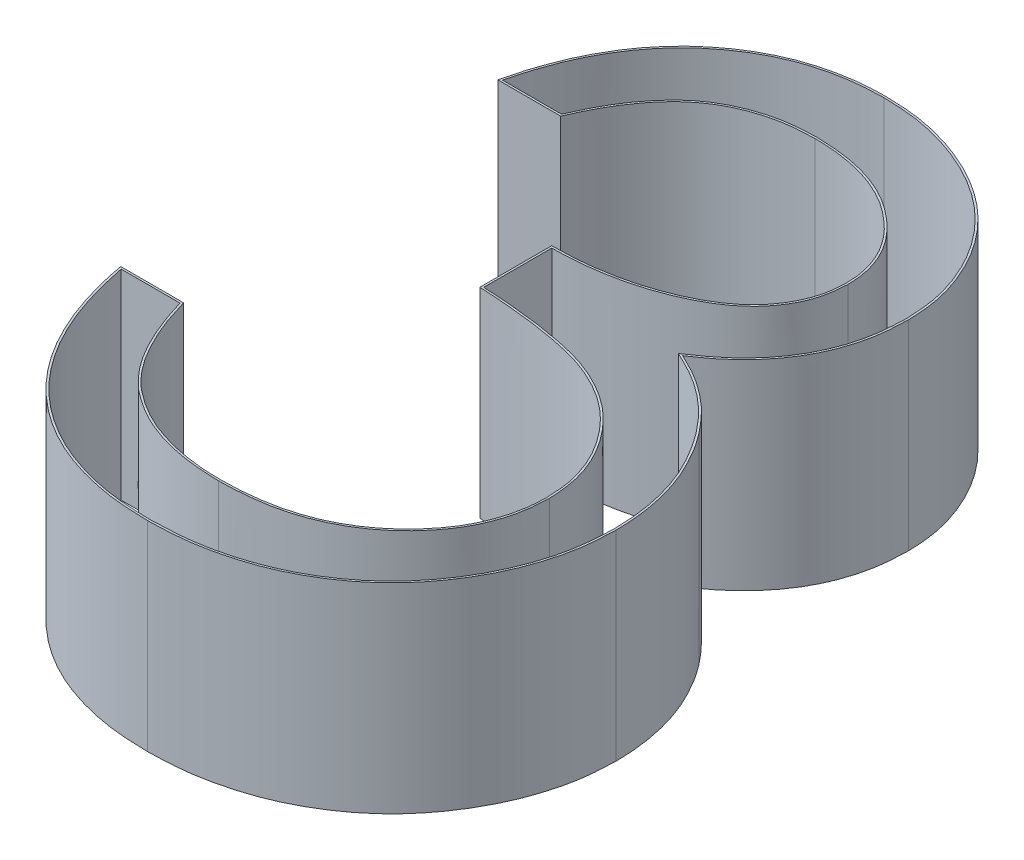
from build123d import *

# Parameters (mm, degrees)
BOSS_EXTRUDE1_DEPTH = 1
CUT_EXTRUDE1_DEPTH  = 1


with BuildPart() as part:
    # Sketch1 → Boss-Extrude1 (new body)
    with BuildSketch(Plane(origin=(0, 0, 0), x_dir=(1, 0, 0), z_dir=(0, 1, 0))):
        with BuildLine():
            Line((0.583333333, 2.692307692), (0.269230769, 2.692307692))
            add(Edge.make_bspline(
                [(0.269230769, 2.692307692), (0.27774032, 2.727540176), (0.294375795, 2.796416801), (0.329073369, 2.894824062), (0.366872624, 2.987947583), (0.412261729, 3.074043657), (0.461770483, 3.154842559), (0.518493204, 3.228511684), (0.579812927, 3.296924649), (0.647637876, 3.357637887), (0.718766538, 3.412615616), (0.794201158, 3.459490673), (0.872424051, 3.499814826), (0.953977184, 3.533035058), (1.039103356, 3.558060582), (1.127032979, 3.576217387), (1.217996479, 3.588008502), (1.27974407, 3.589159265), (1.311097756, 3.58974359)],
                knots=[0, 0, 0, 0, 0.000108665, 0.000212431, 0.000312691, 0.000409905, 0.000504067, 0.000596618, 0.000688443, 0.000779278, 0.000869306, 0.00095782, 0.001045306, 0.001133058, 0.001221569, 0.001311085, 0.001402223, 0.001496238, 0.001496238, 0.001496238, 0.001496238], degree=3))
            add(Edge.make_bspline(
                [(1.311097756, 3.58974359), (1.356780498, 3.588364359), (1.447149509, 3.585635984), (1.579912556, 3.560721548), (1.707939375, 3.521296415), (1.829828623, 3.466822688), (1.943047056, 3.399635375), (2.043783243, 3.319670638), (2.130671753, 3.228471337), (2.203566131, 3.127738772), (2.26064113, 3.020083263), (2.302727504, 2.909283106), (2.328349185, 2.795601134), (2.331669741, 2.718843855), (2.333333333, 2.680388622)],
                knots=[0, 0, 0, 0, 0.000136936, 0.000270885, 0.000403723, 0.000538055, 0.000670441, 0.000797677, 0.000922646, 0.001047185, 0.00116951, 0.001287103, 0.001401935, 0.001517226, 0.001517226, 0.001517226, 0.001517226], degree=3))
            add(Edge.make_bspline(
                [(2.333333333, 2.680388622), (2.332169742, 2.643381827), (2.329892775, 2.570965273), (2.31055907, 2.465243775), (2.278022807, 2.365602175), (2.232953044, 2.271621013), (2.174611494, 2.183896173), (2.103938797, 2.102230282), (2.020436135, 2.026261124), (1.957157197, 1.982741651), (1.924579327, 1.960336538)],
                knots=[0, 0, 0, 0, 0.000110957, 0.000217125, 0.000321111, 0.000424595, 0.000528824, 0.000636204, 0.000747885, 0.000866393, 0.000866393, 0.000866393, 0.000866393], degree=3))
            add(Edge.make_bspline(
                [(1.924579327, 1.960336538), (1.961811081, 1.942358367), (2.035577956, 1.906738409), (2.136128485, 1.836882652), (2.227406361, 1.756226304), (2.27831008, 1.693283652), (2.303886218, 1.661658654)],
                knots=[0, 0, 0, 0, 0.000123863, 0.000245408, 0.000366052, 0.000487879, 0.000487879, 0.000487879, 0.000487879], degree=3))
            add(Edge.make_bspline(
                [(2.303886218, 1.661658654), (2.32072756, 1.638600902), (2.354134456, 1.592862986), (2.39536999, 1.51932656), (2.432779104, 1.444975071), (2.461929324, 1.367815664), (2.484503191, 1.288742651), (2.500639223, 1.207620255), (2.510663364, 1.124382232), (2.512098916, 1.068069752), (2.512820513, 1.039763622)],
                knots=[0, 0, 0, 0, 8.5583e-05, 0.000169764, 0.000252544, 0.000335098, 0.000416766, 0.000498992, 0.000583001, 0.000667909, 0.000667909, 0.000667909, 0.000667909], degree=3))
            add(Edge.make_bspline(
                [(2.512820513, 1.039763622), (2.511025999, 0.990753901), (2.507445417, 0.892965099), (2.475441343, 0.748490377), (2.425828102, 0.607264875), (2.355371166, 0.472190036), (2.269503657, 0.345809655), (2.167346333, 0.232733346), (2.050059925, 0.135534741), (1.919254276, 0.054324513), (1.777537148, -0.010593409), (1.625961556, -0.055650852), (1.466711502, -0.084996852), (1.357504204, -0.08814372), (1.301983173, -0.08974359)],
                knots=[0, 0, 0, 0, 0.000146863, 0.000293035, 0.000441833, 0.000594857, 0.000748684, 0.000899086, 0.001050437, 0.001204129, 0.001359752, 0.001516561, 0.001677477, 0.001843893, 0.001843893, 0.001843893, 0.001843893], degree=3))
            add(Edge.make_bspline(
                [(1.301983173, -0.08974359), (1.264563873, -0.088875376), (1.190935168, -0.087167022), (1.082691669, -0.075488421), (0.97936997, -0.054158416), (0.880830372, -0.025455111), (0.786985336, 0.010936632), (0.698121231, 0.05625533), (0.613691337, 0.109566832), (0.534492386, 0.171500419), (0.460533818, 0.240781759), (0.393781094, 0.318640769), (0.333121301, 0.403638173), (0.280178662, 0.496761229), (0.23254171, 0.596806487), (0.193360753, 0.705054985), (0.158875184, 0.820539007), (0.14284172, 0.901016747), (0.134615385, 0.942307692)],
                knots=[0, 0, 0, 0, 0.000112258, 0.000220887, 0.000326076, 0.000428356, 0.000528479, 0.000627563, 0.000727152, 0.000827569, 0.00092875, 0.001030654, 0.001134734, 0.001241526, 0.001351611, 0.001466743, 0.00158655, 0.001712791, 0.001712791, 0.001712791, 0.001712791], degree=3))
            Line((0.134615385, 0.942307692), (0.448717949, 0.942307692))
            add(Edge.make_bspline(
                [(0.448717949, 0.942307692), (0.45690124, 0.915358679), (0.472818453, 0.862940507), (0.499912751, 0.787500202), (0.530781023, 0.718342149), (0.563895582, 0.654959027), (0.598674028, 0.596726624), (0.637588953, 0.545184755), (0.677758098, 0.498069553), (0.708037451, 0.471524941), (0.722856571, 0.458533654)],
                knots=[0, 0, 0, 0, 8.4487e-05, 0.000164335, 0.000240293, 0.00031148, 0.000378817, 0.000443461, 0.000505064, 0.000564113, 0.000564113, 0.000564113, 0.000564113], degree=3))
            add(Edge.make_bspline(
                [(0.722856571, 0.458533654), (0.742453147, 0.44342532), (0.78158581, 0.413255288), (0.845354041, 0.37475366), (0.912418927, 0.341392634), (0.984233601, 0.315908939), (1.059248372, 0.294331278), (1.138675737, 0.280210759), (1.221814954, 0.270522587), (1.278582718, 0.269667656), (1.307592147, 0.269230769)],
                knots=[0, 0, 0, 0, 7.418e-05, 0.000148131, 0.000223072, 0.000298488, 0.0003764, 0.000456984, 0.000540217, 0.000627201, 0.000627201, 0.000627201, 0.000627201], degree=3))
            add(Edge.make_bspline(
                [(1.307592147, 0.269230769), (1.34034565, 0.269846674), (1.404392297, 0.271051024), (1.497847156, 0.282126731), (1.586754604, 0.298257144), (1.67012753, 0.323170127), (1.749058037, 0.353950979), (1.822439687, 0.392599384), (1.891235793, 0.437944106), (1.954565198, 0.489483264), (2.011510706, 0.545904759), (2.061650219, 0.60491783), (2.10427488, 0.66627366), (2.138658459, 0.730311781), (2.165809009, 0.79676701), (2.18429221, 0.865825839), (2.197143725, 0.936923105), (2.198190337, 0.985252074), (2.198717949, 1.009615385)],
                knots=[0, 0, 0, 0, 9.822e-05, 0.00019206, 0.00028199, 0.000368957, 0.000452673, 0.000535779, 0.000617257, 0.000699492, 0.000780303, 0.000857417, 0.000931514, 0.001003978, 0.001075065, 0.001146335, 0.001218144, 0.001291145, 0.001291145, 0.001291145, 0.001291145], degree=3))
            add(Edge.make_bspline(
                [(2.198717949, 1.009615385), (2.197187647, 1.042226723), (2.194134659, 1.107287132), (2.170826079, 1.203004706), (2.132487215, 1.295228118), (2.078814704, 1.382383909), (2.013478975, 1.46315981), (1.937114068, 1.535231293), (1.84908584, 1.594701384), (1.768065971, 1.63579004), (1.696300814, 1.663827115), (1.63488543, 1.68250208), (1.566128827, 1.698315735), (1.490862478, 1.713028007), (1.408519261, 1.725549355), (1.319188823, 1.735991171), (1.222853062, 1.744346212), (1.156161896, 1.748077307), (1.121794872, 1.75)],
                knots=[0, 0, 0, 0, 9.7761e-05, 0.000195035, 0.000293731, 0.000396299, 0.00050098, 0.000604654, 0.000710058, 0.000818548, 0.000876487, 0.000941025, 0.001010919, 0.001088059, 0.001171055, 0.001260716, 0.001357836, 0.001461094, 0.001461094, 0.001461094, 0.001461094], degree=3))
            Line((1.121794872, 1.75), (1.121794872, 2.108974359))
            add(Edge.make_bspline(
                [(1.121794872, 2.108974359), (1.165096038, 2.109709163), (1.249912384, 2.111148463), (1.373806689, 2.128556473), (1.492280001, 2.152637101), (1.602706743, 2.189522293), (1.703355456, 2.23236259), (1.790675058, 2.2822148), (1.863442206, 2.337629549), (1.921303277, 2.399462158), (1.964832506, 2.465777206), (1.996659303, 2.534893864), (2.015459629, 2.607417924), (2.017969296, 2.656912592), (2.019230769, 2.681790865)],
                knots=[0, 0, 0, 0, 0.0001298, 0.000254247, 0.000374709, 0.000491998, 0.000602842, 0.000702416, 0.000792872, 0.000876214, 0.000955164, 0.001029842, 0.001103644, 0.00117823, 0.00117823, 0.00117823, 0.00117823], degree=3))
            add(Edge.make_bspline(
                [(2.019230769, 2.681790865), (2.018816358, 2.700068611), (2.017991907, 2.736431318), (2.00759463, 2.789556386), (1.991970589, 2.841057332), (1.970490859, 2.890715142), (1.941740661, 2.938185416), (1.907334674, 2.983872865), (1.866366574, 3.027516644), (1.819421127, 3.068196964), (1.769009322, 3.106966201), (1.713759547, 3.139879838), (1.655337672, 3.1680249), (1.593679017, 3.191234402), (1.528583487, 3.20869369), (1.460356929, 3.221229532), (1.388869246, 3.229067187), (1.340097514, 3.230195602), (1.315304487, 3.230769231)],
                knots=[0, 0, 0, 0, 5.4759e-05, 0.000108941, 0.000161726, 0.000216044, 0.000270754, 0.000327825, 0.00038735, 0.000449943, 0.000514025, 0.000577874, 0.000642472, 0.000708366, 0.000775209, 0.000844379, 0.000916308, 0.00099068, 0.00099068, 0.00099068, 0.00099068], degree=3))
            add(Edge.make_bspline(
                [(1.315304487, 3.230769231), (1.275452819, 3.229377869), (1.197613243, 3.226660215), (1.085398326, 3.202857202), (0.981078992, 3.164879118), (0.901340325, 3.119546099), (0.842457751, 3.074795665), (0.800380813, 3.035713279), (0.759060303, 2.992280455), (0.721214626, 2.94182208), (0.682940649, 2.887755289), (0.648096087, 2.827331608), (0.614236395, 2.762127214), (0.593833846, 2.716031579), (0.583333333, 2.692307692)],
                knots=[0, 0, 0, 0, 0.00011944, 0.000233294, 0.000342435, 0.0004514, 0.000506931, 0.000563998, 0.000623523, 0.000686492, 0.000753006, 0.000822147, 0.000895524, 0.000973336, 0.000973336, 0.000973336, 0.000973336], degree=3))
        make_face()
    extrude(amount=BOSS_EXTRUDE1_DEPTH)

    # Sketch2 → Cut-Extrude1 (cut)
    with BuildSketch(Plane(origin=(0, 1, 0), x_dir=(1, 0, 0), z_dir=(0, 1, 0))):
        with BuildLine():
            Line((1.131794872, 2.099143788), (1.131794872, 1.759455761))
            add(Edge.make_bspline(
                [(1.131794872, 1.759455761), (1.25400963, 1.75260213), (1.375889614, 1.742804654), (1.556768615, 1.711040451), (1.616994146, 1.698634438), (1.733029381, 1.662408543), (1.78896901, 1.637957168), (1.896071189, 1.576994529), (1.945335557, 1.541207457), (2.033211027, 1.456447573), (2.072519053, 1.408167942), (2.138259941, 1.305643429), (2.164868095, 1.249333061), (2.200171839, 1.131995595), (2.205842586, 1.071125017), (2.208723028, 1.009741648)],
                knots=[0, 0, 0, 0, 0.25, 0.25, 0.375, 0.375, 0.5, 0.5, 0.625, 0.625, 0.75, 0.75, 0.875, 0.875, 1, 1, 1, 1], degree=3))
            add(Edge.make_bspline(
                [(2.208723028, 1.009741648), (2.207536831, 0.954967155), (2.202299228, 0.900896464), (2.176531715, 0.795411633), (2.156623965, 0.743531625), (2.079916828, 0.600072131), (2.005433886, 0.516630718), (1.835432126, 0.382072779), (1.735938218, 0.332336594), (1.527482685, 0.270900484), (1.417098812, 0.261288193), (1.307610865, 0.259229353)],
                knots=[0, 0, 0, 0, 0.125, 0.125, 0.25, 0.25, 0.5, 0.5, 0.75, 0.75, 1, 1, 1, 1], degree=3))
            add(Edge.make_bspline(
                [(1.307610865, 0.259229353), (1.201613817, 0.260825686), (1.095479681, 0.271848515), (0.943246939, 0.318831934), (0.894321154, 0.338184952), (0.802004391, 0.387814601), (0.75862563, 0.41832993), (0.716501346, 0.450806406)],
                knots=[0, 0, 0, 0, 0.5, 0.5, 0.75, 0.75, 1, 1, 1, 1], degree=3))
            add(Edge.make_bspline(
                [(0.716501346, 0.450806406), (0.681034504, 0.481898668), (0.648360609, 0.515661907), (0.590618735, 0.590351015), (0.566276068, 0.630165458), (0.500444041, 0.753533738), (0.468620139, 0.842415383), (0.441304166, 0.932307692)],
                knots=[0, 0, 0, 0, 0.25, 0.25, 0.5, 0.5, 1, 1, 1, 1], degree=3))
            Line((0.441304166, 0.932307692), (0.14680605, 0.932307692))
            add(Edge.make_bspline(
                [(0.14680605, 0.932307692), (0.174400485, 0.794123548), (0.212478515, 0.659842992), (0.335333215, 0.408670218), (0.417998917, 0.291119186), (0.627797422, 0.102792419), (0.75074063, 0.030611697), (0.952375764, -0.037540193), (1.020737542, -0.054294926), (1.159869261, -0.075319197), (1.230981109, -0.078093472), (1.301955116, -0.079740247)],
                knots=[0, 0, 0, 0, 0.25, 0.25, 0.5, 0.5, 0.75, 0.75, 0.875, 0.875, 1, 1, 1, 1], degree=3))
            add(Edge.make_bspline(
                [(1.301955116, -0.079740247), (1.378380452, -0.077537994), (1.454661753, -0.074481462), (1.604109762, -0.04989562), (1.677792161, -0.031424897), (1.895296349, 0.045001008), (2.028690719, 0.123780991), (2.253614802, 0.329956157), (2.342852232, 0.457440875), (2.437241764, 0.664763811), (2.46138045, 0.736854079), (2.495274559, 0.886891658), (2.500012725, 0.963264356), (2.502815847, 1.039819208)],
                knots=[0, 0, 0, 0, 0.125, 0.125, 0.25, 0.25, 0.5, 0.5, 0.75, 0.75, 0.875, 0.875, 1, 1, 1, 1], degree=3))
            add(Edge.make_bspline(
                [(2.502815847, 1.039819208), (2.50140525, 1.095151381), (2.498518056, 1.150365049), (2.481157888, 1.25986256), (2.468254655, 1.313628939), (2.41565585, 1.471403208), (2.361081695, 1.566397029), (2.29595602, 1.655561727)],
                knots=[0, 0, 0, 0, 0.25, 0.25, 0.5, 0.5, 1, 1, 1, 1], degree=3))
            add(Edge.make_bspline(
                [(2.29595602, 1.655561727), (2.269980707, 1.687680284), (2.243941446, 1.719885975), (2.215229662, 1.749583652), (2.186445309, 1.779356388), (2.155048212, 1.806694438), (2.089258054, 1.857504786), (2.054521874, 1.880995565), (2.018179255, 1.901472949), (1.981261763, 1.922274248), (1.942883917, 1.940392966), (1.904725217, 1.958818734)],
                knots=[0, 0, 0, 0, 0.000123923, 0.000123923, 0.000123923, 0.00024831, 0.00024831, 0.000373617, 0.000373617, 0.000373617, 0.000500675, 0.000500675, 0.000500675, 0.000500675], degree=3))
            add(Edge.make_bspline(
                [(1.904725217, 1.958818734), (1.96489512, 2.000199998), (2.024814814, 2.042043711), (2.130070027, 2.144010649), (2.175759656, 2.200147166), (2.250606558, 2.324699289), (2.279001642, 2.393108804), (2.315488065, 2.533121557), (2.321016289, 2.606856651), (2.323326535, 2.680329575)],
                knots=[0, 0, 0, 0, 0.25, 0.25, 0.5, 0.5, 0.75, 0.75, 1, 1, 1, 1], degree=3))
            add(Edge.make_bspline(
                [(2.323326535, 2.680329575), (2.320614291, 2.743023856), (2.316136277, 2.805371619), (2.286684666, 2.926045052), (2.264205777, 2.985601186), (2.181368129, 3.154021651), (2.102115637, 3.254859469), (1.911203249, 3.415154571), (1.798702642, 3.476268348), (1.621620076, 3.538400873), (1.560241504, 3.554539137), (1.436598884, 3.575279423), (1.373858767, 3.577844169), (1.31104, 3.579740777)],
                knots=[0, 0, 0, 0, 0.125, 0.125, 0.25, 0.25, 0.5, 0.5, 0.75, 0.75, 0.875, 0.875, 1, 1, 1, 1], degree=3))
            add(Edge.make_bspline(
                [(1.31104, 3.579740777), (1.249383665, 3.578591691), (1.188091815, 3.575225005), (1.067735245, 3.554941313), (1.008144425, 3.540394723), (0.833389517, 3.477408481), (0.729052414, 3.41408403), (0.542448143, 3.251871286), (0.467983704, 3.153911248), (0.350337559, 2.937680714), (0.310939212, 2.822014718), (0.281936667, 2.702307692)],
                knots=[0, 0, 0, 0, 0.125, 0.125, 0.25, 0.25, 0.5, 0.5, 0.75, 0.75, 1, 1, 1, 1], degree=3))
            Line((0.281936667, 2.702307692), (0.576824248, 2.702307692))
            add(Edge.make_bspline(
                [(0.576824248, 2.702307692), (0.609928925, 2.777056115), (0.645639158, 2.850260304), (0.738025257, 2.984242983), (0.791577879, 3.047602613), (0.920036772, 3.146811482), (0.995007165, 3.183464339), (1.111948159, 3.218631693), (1.152280845, 3.227534865), (1.233401404, 3.237910806), (1.274323277, 3.239344525), (1.315245629, 3.240773269)],
                knots=[0, 0, 0, 0, 0.25, 0.25, 0.5, 0.5, 0.75, 0.75, 0.875, 0.875, 1, 1, 1, 1], degree=3))
            add(Edge.make_bspline(
                [(1.315245629, 3.240773269), (1.399233206, 3.238830075), (1.48213228, 3.231247265), (1.642554783, 3.188230037), (1.721455986, 3.15267002), (1.857261228, 3.05400656), (1.918867726, 2.994345033), (1.984940896, 2.885848374), (2.001192531, 2.846986296), (2.023709197, 2.766574972), (2.0282745, 2.724080835), (2.029236515, 2.681650809)],
                knots=[0, 0, 0, 0, 0.25, 0.25, 0.5, 0.5, 0.75, 0.75, 0.875, 0.875, 1, 1, 1, 1], degree=3))
            add(Edge.make_bspline(
                [(2.029236515, 2.681650809), (2.026731311, 2.63224417), (2.021631762, 2.583329171), (1.989329445, 2.489687837), (1.965433125, 2.445767061), (1.877238557, 2.326773171), (1.793032915, 2.267596139), (1.616514058, 2.180787168), (1.522525696, 2.149017148), (1.37731315, 2.119486394), (1.328673315, 2.111588429), (1.230725125, 2.101312006), (1.181287436, 2.100001362), (1.131794872, 2.099143788)],
                knots=[0, 0, 0, 0, 0.125, 0.125, 0.25, 0.25, 0.5, 0.5, 0.75, 0.75, 0.875, 0.875, 1, 1, 1, 1], degree=3))
        make_face()
    extrude(amount=-CUT_EXTRUDE1_DEPTH, mode=Mode.SUBTRACT)


solid = part.part
